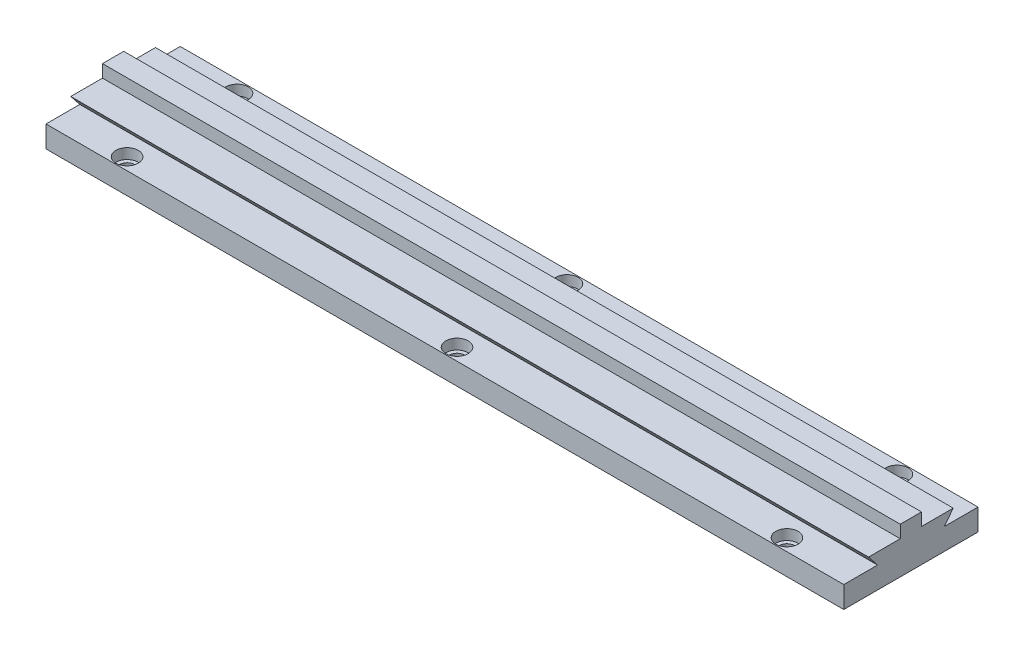
from build123d import *

# Parameters (mm, degrees)
BOSS_EXTRUDE1_DEPTH                              = 368.5
CBORE_FOR_1_4_SOCKET_SHOULDER_SCREW1_D           = 6.7564
CBORE_FOR_1_4_SOCKET_SHOULDER_SCREW1_CBORE_D     = 10.31748
CBORE_FOR_1_4_SOCKET_SHOULDER_SCREW1_CBORE_DEPTH = 4.7752


with BuildPart() as part:
    # Sketch1 → Boss-Extrude1 (new body)
    with BuildSketch(Plane(origin=(0, 0, 0), x_dir=(0, 0, -1), z_dir=(1, 0, 0))):
        Polygon((-31, 0), (31, 0), (31, 10), (15.4, 10), (19.57, 15.28), (4.91, 15.28), (4.91, 21.1), (-4.91, 21.1), (-4.91, 15.28), (-19.57, 15.28), (-15.4, 10), (-31, 10), align=None)
    extrude(amount=BOSS_EXTRUDE1_DEPTH)

    # CBORE for 1/4 Socket Shoulder Screw1 (through all)
    with Locations(Plane(origin=(0, 10, 0), x_dir=(1, 0, 0), z_dir=(0, 1, 0))):
        with Locations((31.85, 25.4), (184.25, 25.4), (336.65, 25.4), (336.65, -25.4), (184.25, -25.4), (31.85, -25.4)):
            CounterBoreHole(CBORE_FOR_1_4_SOCKET_SHOULDER_SCREW1_D / 2, CBORE_FOR_1_4_SOCKET_SHOULDER_SCREW1_CBORE_D / 2, CBORE_FOR_1_4_SOCKET_SHOULDER_SCREW1_CBORE_DEPTH)


solid = part.part
